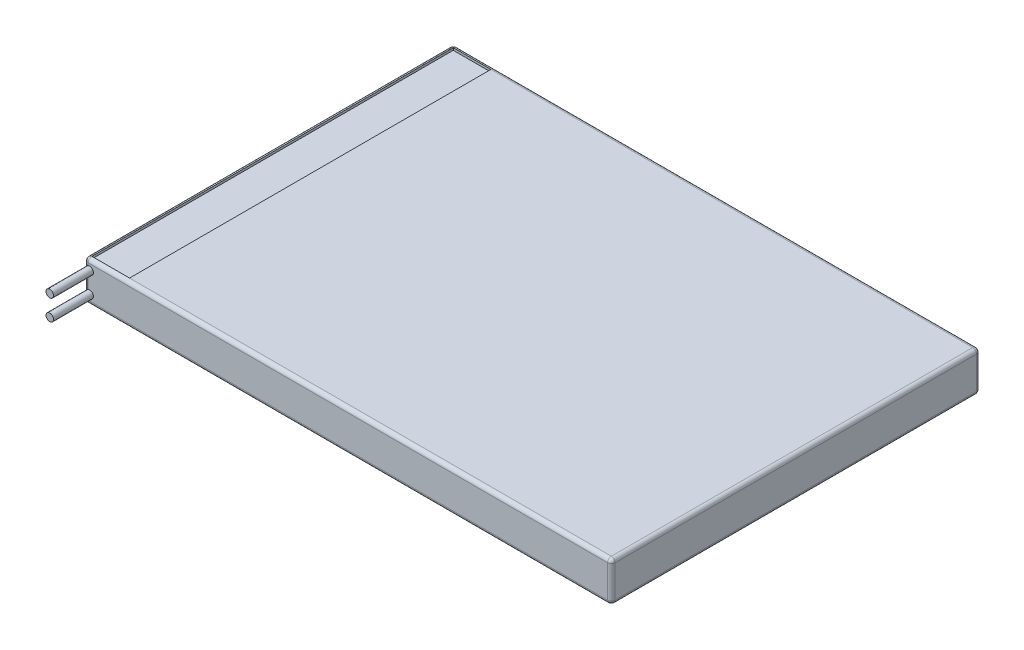
from build123d import *

# Parameters (mm, degrees)
BOSS_EXTRUDE2_DEPTH      = 5.3
SKETCH2_R                = 0.5
BOSS_EXTRUDE3_DEPTH      = 5.3
BOSS_EXTRUDE3_DEPTH_BACK = 1
FILLET2_R                = 0.5
SKETCH4_W                = 5
SKETCH4_H                = 48
CUT_EXTRUDE1_DEPTH       = 0.3


with BuildPart() as part:
    # Sketch1 → Boss-Extrude2 (new body)
    with BuildSketch(Plane(origin=(0, 0, 0), x_dir=(1, 0, 0), z_dir=(0, 1, 0))):
        with BuildLine():
            Line((-34.5, -24.5), (34.5, -24.5))
            ThreePointArc((34.5, -24.5), (34.853553391, -24.353553391), (35, -24))
            Line((35, -24), (35, 24))
            ThreePointArc((35, 24), (34.853553391, 24.353553391), (34.5, 24.5))
            Line((34.5, 24.5), (-34.5, 24.5))
            ThreePointArc((-34.5, 24.5), (-34.853553391, 24.353553391), (-35, 24))
            Line((-35, 24), (-35, -24))
            ThreePointArc((-35, -24), (-34.853553391, -24.353553391), (-34.5, -24.5))
        make_face()
    extrude(amount=BOSS_EXTRUDE2_DEPTH)

    # Sketch2 → Boss-Extrude3 (add, two sides)
    with BuildSketch(Plane.XY.offset(24.5)) as boss_extrude3_sk:
        with Locations((-34.3, 1.279563796)):
            Circle(SKETCH2_R)
        with Locations((-34.3, 4.020436204)):
            Circle(SKETCH2_R)
    extrude(amount=BOSS_EXTRUDE3_DEPTH)
    extrude(boss_extrude3_sk.sketch, amount=-BOSS_EXTRUDE3_DEPTH_BACK)

    # Fillet2
    fillet2_edges = [part.edges().sort_by_distance(p)[0] for p in [
        (34.853553391, 5.3, 24.353553391),
        (0, 0, 24.5),
        (-34.853553391, 0, 24.353553391),
        (35, 5.3, 0),
        (34.853553391, 5.3, -24.353553391),
        (0, 5.3, -24.5),
        (-34.853553391, 5.3, -24.353553391),
        (-35, 5.3, 0),
        (-34.853553391, 5.3, 24.353553391),
        (0, 5.3, 24.5),
        (-35, 0, 0),
        (-34.853553391, 0, -24.353553391),
        (0, 0, -24.5),
        (34.853553391, 0, -24.353553391),
        (35, 0, 0),
        (34.853553391, 0, 24.353553391),
    ]]
    fillet(fillet2_edges, radius=FILLET2_R)

    # Sketch4 → Cut-Extrude1 (cut)
    with BuildSketch(Plane(origin=(0, 5.3, 0), x_dir=(1, 0, 0), z_dir=(0, 1, 0))):
        with Locations((-32, 0)):
            Rectangle(SKETCH4_W, SKETCH4_H)
    extrude(amount=-CUT_EXTRUDE1_DEPTH, mode=Mode.SUBTRACT)


solid = part.part
